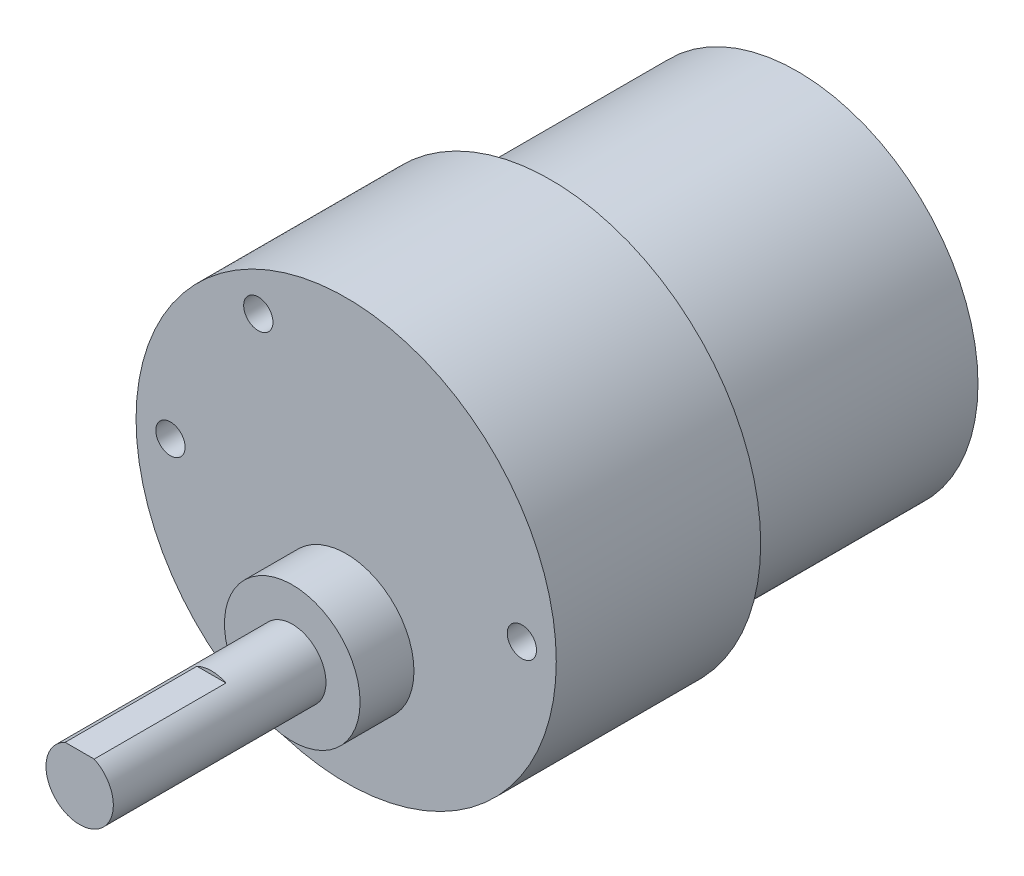
from build123d import *

# Parameters (mm, degrees)
SKETCH1_R          = 15.6591
MOTOR_DEPTH        = 21.4122
SKETCH3_R          = 18.2245
GEARBOX_DEPTH      = 17.7292
SKETCH4_R          = 5.8801
PROTRUSION_DEPTH   = 4.6736
SKETCH5_R          = 2.921
SHAFT_DEPTH        = 18.4404
SKETCH6_R          = 1.27
SCREW_HOLES_DEPTH  = 9.3472
SKETCH7_R          = 4.4577
NUB_DEPTH          = 2.921
CUT_EXTRUDE1_DEPTH = 11.43


with BuildPart() as part:
    # Sketch1 → motor (new body)
    with BuildSketch(Plane.XY):
        Circle(SKETCH1_R)
    extrude(amount=MOTOR_DEPTH)

    # Sketch3 → gearbox (add)
    with BuildSketch(Plane.XY.offset(21.4122)):
        Circle(SKETCH3_R)
    extrude(amount=GEARBOX_DEPTH)

    # Sketch4 → protrusion (add)
    with BuildSketch(Plane.XY.offset(39.1414)):
        with Locations((0, -6.8834)):
            Circle(SKETCH4_R)
    extrude(amount=PROTRUSION_DEPTH)

    # Sketch5 → shaft (add)
    with BuildSketch(Plane.XY.offset(43.815)):
        with Locations((0, -6.8834)):
            Circle(SKETCH5_R)
    extrude(amount=SHAFT_DEPTH)

    # Sketch6 → screw holes (cut)
    with BuildSketch(Plane.XY.offset(39.1414)):
        with Locations((15.24, 0)):
            Circle(SKETCH6_R)
        with Locations((-15.24, 0)):
            Circle(SKETCH6_R)
        with Locations((-7.62, -13.198227096)):
            Circle(SKETCH6_R)
        with Locations((-7.61999995, 13.198227183)):
            Circle(SKETCH6_R)
    extrude(amount=-SCREW_HOLES_DEPTH, mode=Mode.SUBTRACT)

    # Sketch7 → nub (add)
    with BuildSketch(Plane(origin=(0, 0, 0), x_dir=(-1, 0, 0), z_dir=(0, 0, -1))):
        Circle(SKETCH7_R)
    extrude(amount=NUB_DEPTH)

    # Sketch8 → Cut-Extrude1 (cut)
    with BuildSketch(Plane.XY.offset(62.2554)):
        with BuildLine():
            Line((1.260039062, -4.24815), (-1.260039062, -4.24815))
            ThreePointArc((-1.260039062, -4.24815), (0, -3.9624), (1.260039062, -4.24815))
        make_face()
    extrude(amount=-CUT_EXTRUDE1_DEPTH, mode=Mode.SUBTRACT)


solid = part.part
